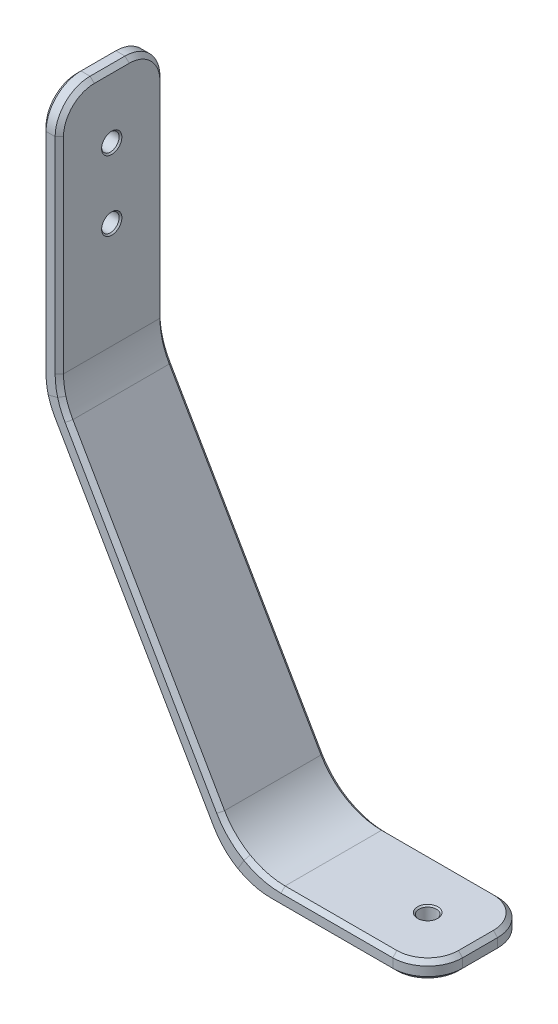
from build123d import *

# Parameters (mm, degrees)
SKETCH2_W                    = 3.175
SKETCH2_H                    = 19.05
F_1_8_0_125_DIAMETER_HOLE1_D = 3.175
F_1_8_0_125_DIAMETER_HOLE2_D = 3.175
FILLET1_R                    = 12.7
FILLET2_R                    = 6.35
CHAMFER3_SIZE                = 0.762
CHAMFER2_SIZE                = 0.254


with BuildPart() as part:
    # Sweep1: sweep along a path in Sketch1
    with BuildLine(Plane.XY) as sweep1_path:
        Line((0, 0), (0, -47.5145354))
        Line((0, -47.5145354), (33.61082832, -105.730197734))
        Line((33.61082832, -105.730197734), (68.53582832, -105.730197734))
    # Sketch2 → Sweep1 (sweep)
    with BuildSketch(Plane(origin=(0, 0, 0), x_dir=(1, 0, 0), z_dir=(0, 1, 0))):
        Rectangle(SKETCH2_W, SKETCH2_H)
    sweep(path=sweep1_path.line, transition=Transition.RIGHT)

    # 1/8 (0.125) Diameter Hole1 (through all)
    with Locations(Plane(origin=(1.5875, 0, 0), x_dir=(0, 0, -1), z_dir=(1, 0, 0))):
        with Locations((0, -11.693565329), (0, -24.393565329)):
            Hole(F_1_8_0_125_DIAMETER_HOLE1_D / 2)

    # 1/8 (0.125) Diameter Hole2 (through all)
    with Locations(Plane(origin=(0, -104.142697734, 0), x_dir=(1, 0, 0), z_dir=(0, 1, 0))):
        with Locations((59.01082832, 0)):
            Hole(F_1_8_0_125_DIAMETER_HOLE2_D / 2)

    # Fillet1
    fillet1_edges = [part.edges().sort_by_distance(p)[0] for p in [
        (1.5875, -47.089166057, 0),
        (-1.5875, -47.939904743, 0),
        (32.694284767, -107.317697734, 0),
        (34.527371872, -104.142697734, 0),
    ]]
    fillet(fillet1_edges, radius=FILLET1_R)

    # Fillet2
    fillet2_edges = [part.edges().sort_by_distance(p)[0] for p in [
        (0, 0, -9.525),
        (0, 0, 9.525),
        (68.53582832, -105.730197734, -9.525),
        (68.53582832, -105.730197734, 9.525),
    ]]
    fillet(fillet2_edges, radius=FILLET2_R)

    # Chamfer3
    chamfer3_edges = [part.edges().sort_by_distance(p)[0] for p in [
        (68.53582832, -107.317697734, 0),
        (66.67595638, -107.317697734, 7.665128061),
        (66.67595638, -107.317697734, -7.665128061),
        (68.53582832, -104.142697734, 0),
        (66.67595638, -104.142697734, 7.665128061),
        (66.67595638, -104.142697734, -7.665128061),
        (1.5875, 0, 0),
        (-1.5875, 0, 0),
        (-1.5875, -25.443475, -9.525),
        (-1.5875, -25.443475, 9.525),
        (-1.5875, -1.859871939, 7.665128061),
        (-1.5875, -1.859871939, -7.665128061),
        (1.5875, -25.018105657, -9.525),
        (1.5875, -25.018105657, 9.525),
        (1.5875, -1.859871939, 7.665128061),
        (1.5875, -1.859871939, -7.665128061),
        (51.106230753, -107.317697734, -9.525),
        (51.106230753, -107.317697734, 9.525),
        (52.022774305, -104.142697734, -9.525),
        (33.676633186, -105.616220362, -9.525),
        (14.571043965, -75.927323867, -9.525),
        (17.075087517, -73.914454524, -9.525),
        (-1.154757994, -47.823951872, -9.525),
        (33.676633186, -105.616220362, -9.525),
        (14.571043965, -75.927323867, 9.525),
        (17.075087517, -73.914454524, 9.525),
        (-1.154757994, -47.823951872, 9.525),
        (33.676633186, -105.616220362, 9.525),
        (52.022774305, -104.142697734, 9.525),
        (33.676633186, -105.616220362, 9.525),
        (-1.154757994, -47.823951872, -9.525),
        (-1.154757994, -47.823951872, 9.525),
        (35.509720291, -102.441220362, 9.525),
        (35.509720291, -102.441220362, 9.525),
        (35.509720291, -102.441220362, -9.525),
        (35.509720291, -102.441220362, -9.525),
        (2.020242006, -46.973213186, 9.525),
        (2.020242006, -46.973213186, 9.525),
        (2.020242006, -46.973213186, -9.525),
        (2.020242006, -46.973213186, -9.525),
    ]]
    chamfer(chamfer3_edges, length=CHAMFER3_SIZE)

    # Chamfer2
    chamfer2_edges = [part.edges().sort_by_distance(p)[0] for p in [
        (1.5875, -24.393565329, -1.5875),
        (-1.5875, -24.393565329, -1.5875),
        (1.5875, -11.693565329, -1.5875),
        (-1.5875, -11.693565329, -1.5875),
        (60.59832832, -104.142697734, 0),
        (60.59832832, -107.317697734, 0),
    ]]
    chamfer(chamfer2_edges, length=CHAMFER2_SIZE)


solid = part.part
